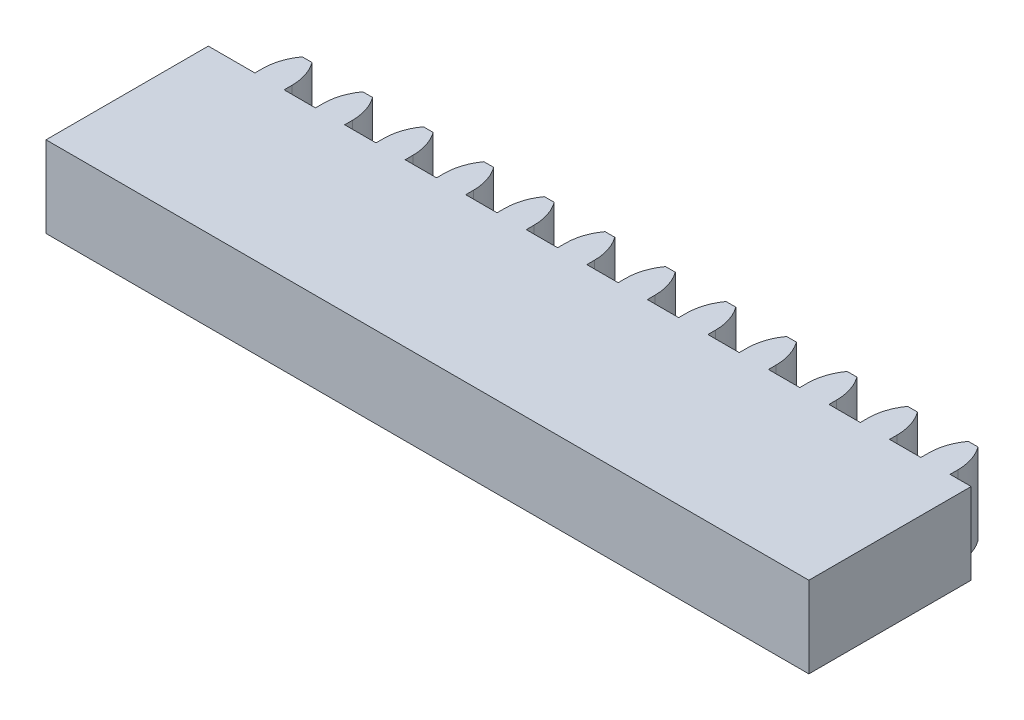
from build123d import *

# Parameters (mm, degrees)
BOSS_EXTRUDE1_DEPTH = 12.7
BOSS_EXTRUDE2_DEPTH = 12.7
LPATTERN1_COUNT     = 12
LPATTERN1_PITCH     = 9.4742


with BuildPart() as part:
    # Sketch1 → Boss-Extrude1 (new body)
    with BuildSketch(Plane(origin=(0, 0, 0), x_dir=(1, 0, 0), z_dir=(0, 1, 0))):
        Polygon((-59.69, 12.7), (-59.69, -12.7), (59.69, -12.7), (59.69, 12.7), (56.388, 12.7), (51.816, 12.7), align=None)
    extrude(amount=BOSS_EXTRUDE1_DEPTH)

    # Sketch1_4 → Boss-Extrude2 (add)
    with BuildSketch(Plane(origin=(0, 0, 0), x_dir=(1, 0, 0), z_dir=(0, 1, 0))):
        with BuildLine():
            Line((51.816, 13.908285481), (51.816, 12.7))
            Line((51.816, 12.7), (56.388, 12.7))
            Line((56.388, 12.7), (56.388, 13.908285481))
            ThreePointArc((56.388, 13.908285481), (55.997429107, 16.372543207), (54.864, 18.595255564))
            Line((54.864, 18.595255564), (53.34, 18.595255564))
            ThreePointArc((53.34, 18.595255564), (52.206570893, 16.372543207), (51.816, 13.908285481))
        make_face()
    boss_extrude2 = extrude(amount=BOSS_EXTRUDE2_DEPTH)

    # LPattern1: Boss-Extrude2 ×12
    with Locations(*[(-i * LPATTERN1_PITCH, 0, 0) for i in range(1, LPATTERN1_COUNT)]):
        add(boss_extrude2)


solid = part.part
